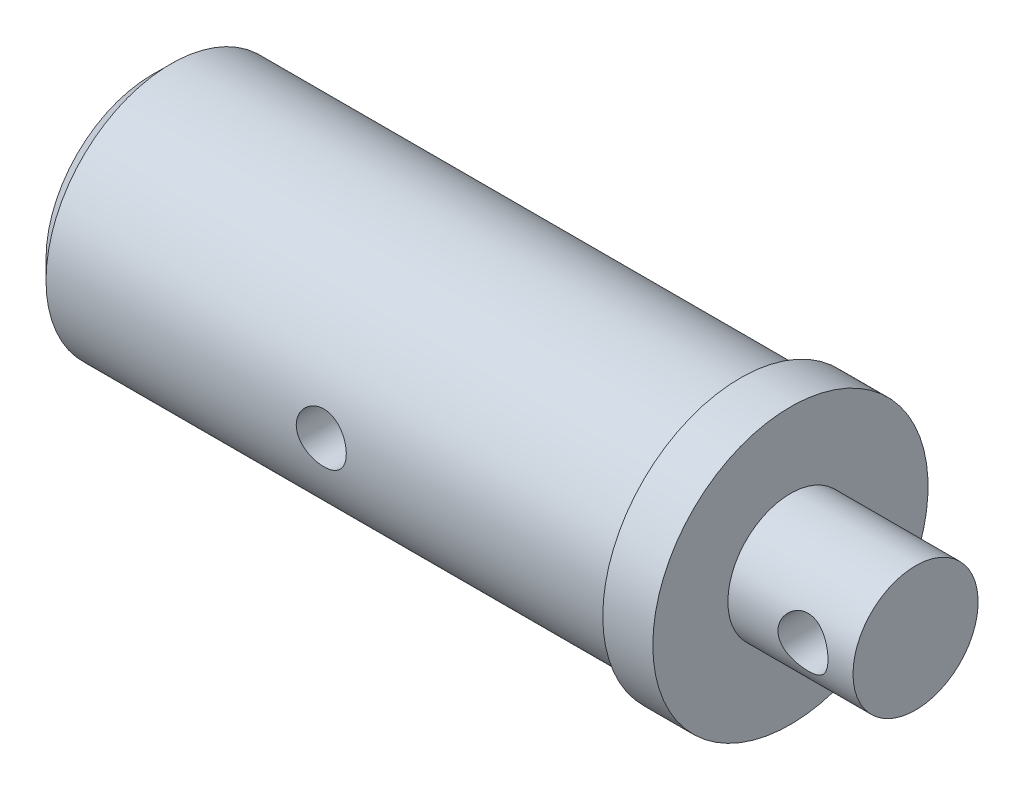
from build123d import *

# Parameters (mm, degrees)
SZKIC3_R                   = 6
WYTNIJ_WYCI_GNI_CIE1_DEPTH = 30
SFAZOWANIE1_SIZE           = 1.5
SZKIC6_R                   = 2
WYTNIJ_WYCI_GNI_CIE4_DEPTH = 15


with BuildPart() as part:
    # Szkic1 → Obrót1 (revolve)
    with BuildSketch(Plane(origin=(0, 0, 0), x_dir=(1, 0, 0), z_dir=(0, 1, 0))):
        Polygon((-22, 0), (39, 0), (39, 5), (29, 5), (29, 11), (25, 11), (25, 10), (-22, 10), align=None)
    revolve(axis=Axis((-22, 0, 0), (1, 0, 0)))

    # Szkic3 → Wytnij-wyciągnięcie1 (cut)
    with BuildSketch(Plane.ZY.offset(22)):
        Circle(SZKIC3_R)
    extrude(amount=-WYTNIJ_WYCI_GNI_CIE1_DEPTH, mode=Mode.SUBTRACT)

    # Sfazowanie1
    sfazowanie1_edges = [part.edges().sort_by_distance(p)[0] for p in [
        (-22, 0, 10),
    ]]
    chamfer(sfazowanie1_edges, length=SFAZOWANIE1_SIZE)

    # Szkic6 → Wytnij-wyciągnięcie4 (cut, symmetric)
    with BuildSketch(Plane.XY):
        with Locations((35, 0)):
            Circle(SZKIC6_R)
        with Locations((1.5, 0)):
            Circle(SZKIC6_R)
    extrude(amount=WYTNIJ_WYCI_GNI_CIE4_DEPTH, both=True, mode=Mode.SUBTRACT)


solid = part.part
